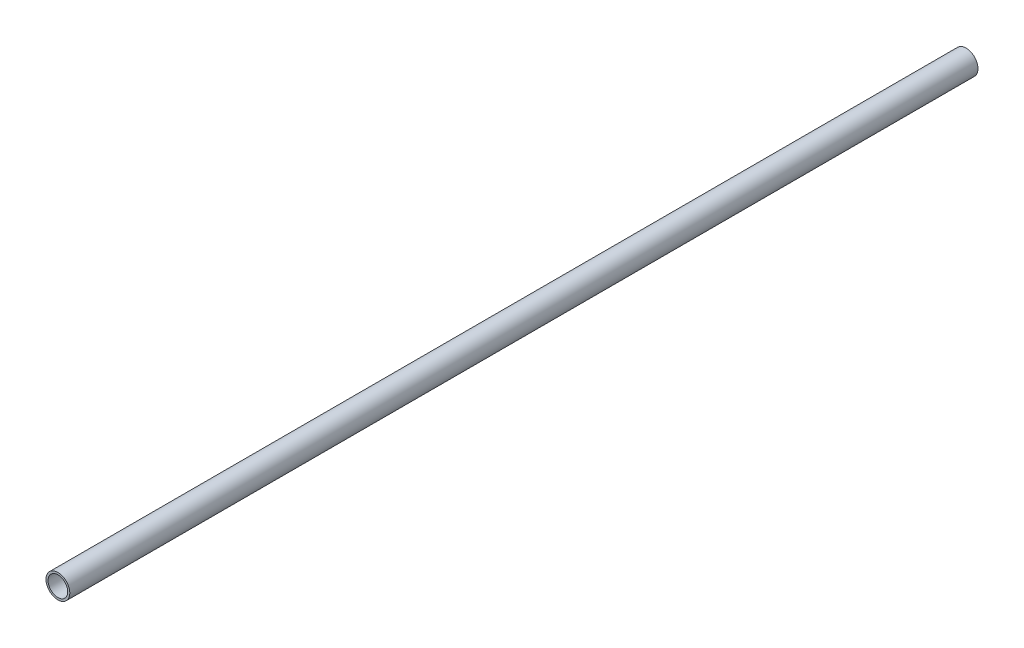
from build123d import *

# Parameters (mm, degrees)
SKETCH1_R           = 5.9944
SKETCH1_R_2         = 4.953
BOSS_EXTRUDE1_DEPTH = 457.2


with BuildPart() as part:
    # Sketch1 → Boss-Extrude1 (new body)
    with BuildSketch(Plane.XY):
        Circle(SKETCH1_R)
        Circle(SKETCH1_R_2, mode=Mode.SUBTRACT)
    extrude(amount=BOSS_EXTRUDE1_DEPTH)


solid = part.part
